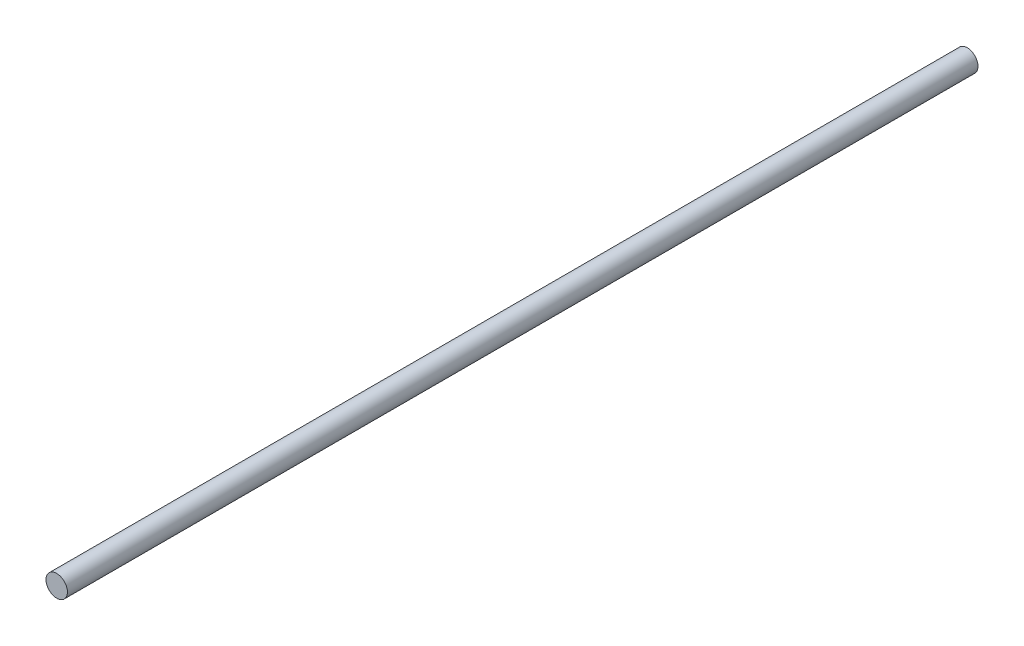
from build123d import *

# Parameters (mm, degrees)
SKETCH1_R      = 2.0955
EXTRUDE1_DEPTH = 88.9


with BuildPart() as part:
    # Sketch1 → Extrude1 (new body, symmetric)
    with BuildSketch(Plane.XY):
        Circle(SKETCH1_R)
    extrude(amount=EXTRUDE1_DEPTH, both=True)


solid = part.part
